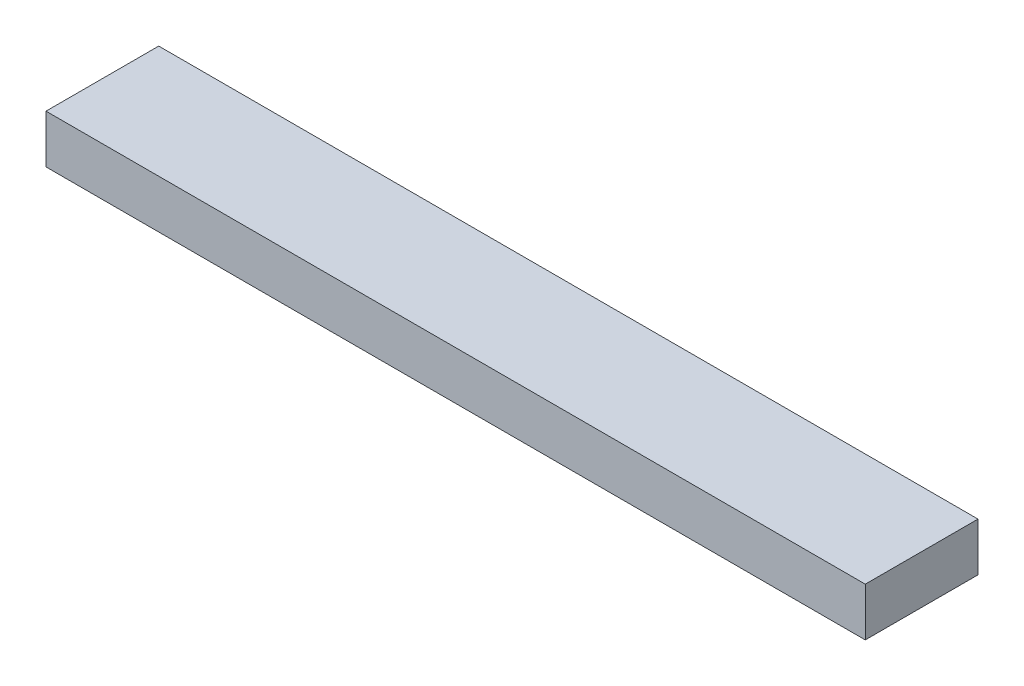
from build123d import *

# Parameters (mm, degrees)
SKETCH1_W           = 646.1125
SKETCH1_H           = 88.9
BOSS_EXTRUDE1_DEPTH = 38.1


with BuildPart() as part:
    # Sketch1 → Boss-Extrude1 (new body)
    with BuildSketch(Plane(origin=(0, 0, 0), x_dir=(1, 0, 0), z_dir=(0, 1, 0))):
        with Locations((323.05625, 44.45)):
            Rectangle(SKETCH1_W, SKETCH1_H)
    extrude(amount=BOSS_EXTRUDE1_DEPTH)


solid = part.part
